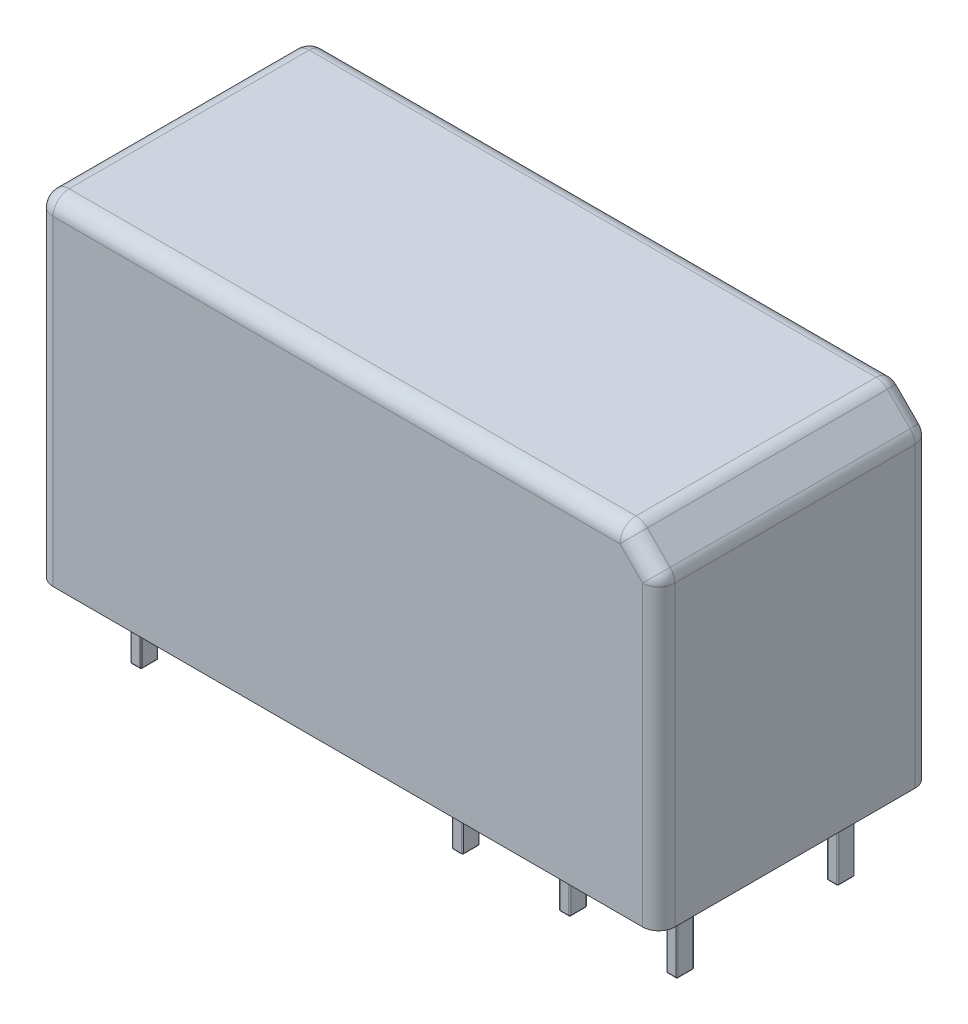
from build123d import *

# Parameters (mm, degrees)
SKETCH_1_W      = 29
SKETCH_1_H      = 12.7
EXTRUDE_1_DEPTH = 15.7
EXTRUDE_2_DEPTH = 3.5
FILLET_1_R      = 0.05
CHAMFER_1_SIZE  = 1.5
FILLET_2_R      = 0.75


with BuildPart() as part:
    # Эскиз1 → Бобышка-Вытянуть1 (new body)
    with BuildSketch(Plane(origin=(0, 0, 0), x_dir=(1, 0, 0), z_dir=(0, 1, 0))):
        Rectangle(SKETCH_1_W, SKETCH_1_H)
    extrude(amount=EXTRUDE_1_DEPTH)

    # Эскиз2 → Бобышка-Вытянуть2 (add)
    with BuildSketch(Plane.XZ):
        with BuildLine():
            Line((-12.3, 4.15), (-11.9, 4.15))
            ThreePointArc((-11.9, 4.15), (-11.864644661, 4.135355339), (-11.85, 4.1))
            Line((-11.85, 4.1), (-11.85, 3.4))
            ThreePointArc((-11.85, 3.4), (-11.864644661, 3.364644661), (-11.9, 3.35))
            Line((-11.9, 3.35), (-12.3, 3.35))
            ThreePointArc((-12.3, 3.35), (-12.335355339, 3.364644661), (-12.35, 3.4))
            Line((-12.35, 3.4), (-12.35, 4.1))
            ThreePointArc((-12.35, 4.1), (-12.335355339, 4.135355339), (-12.3, 4.15))
        make_face()
        with BuildLine():
            Line((2.65, 4.1), (2.65, 3.4))
            ThreePointArc((2.65, 3.4), (2.664644661, 3.364644661), (2.7, 3.35))
            Line((2.7, 3.35), (3.1, 3.35))
            ThreePointArc((3.1, 3.35), (3.135355339, 3.364644661), (3.15, 3.4))
            Line((3.15, 3.4), (3.15, 4.1))
            ThreePointArc((3.15, 4.1), (3.135355339, 4.135355339), (3.1, 4.15))
            Line((3.1, 4.15), (2.7, 4.15))
            ThreePointArc((2.7, 4.15), (2.664644661, 4.135355339), (2.65, 4.1))
        make_face()
        with BuildLine():
            Line((7.65, 4.1), (7.65, 3.4))
            ThreePointArc((7.65, 3.4), (7.664644661, 3.364644661), (7.7, 3.35))
            Line((7.7, 3.35), (8.1, 3.35))
            ThreePointArc((8.1, 3.35), (8.135355339, 3.364644661), (8.15, 3.4))
            Line((8.15, 3.4), (8.15, 4.1))
            ThreePointArc((8.15, 4.1), (8.135355339, 4.135355339), (8.1, 4.15))
            Line((8.1, 4.15), (7.7, 4.15))
            ThreePointArc((7.7, 4.15), (7.664644661, 4.135355339), (7.65, 4.1))
        make_face()
        with BuildLine():
            Line((12.65, 4.1), (12.65, 3.4))
            ThreePointArc((12.65, 3.4), (12.664644661, 3.364644661), (12.7, 3.35))
            Line((12.7, 3.35), (13.1, 3.35))
            ThreePointArc((13.1, 3.35), (13.135355339, 3.364644661), (13.15, 3.4))
            Line((13.15, 3.4), (13.15, 4.1))
            ThreePointArc((13.15, 4.1), (13.135355339, 4.135355339), (13.1, 4.15))
            Line((13.1, 4.15), (12.7, 4.15))
            ThreePointArc((12.7, 4.15), (12.664644661, 4.135355339), (12.65, 4.1))
        make_face()
        with BuildLine():
            Line((2.65, -3.4), (2.65, -4.1))
            ThreePointArc((2.65, -4.1), (2.664644661, -4.135355339), (2.7, -4.15))
            Line((2.7, -4.15), (3.1, -4.15))
            ThreePointArc((3.1, -4.15), (3.135355339, -4.135355339), (3.15, -4.1))
            Line((3.15, -4.1), (3.15, -3.4))
            ThreePointArc((3.15, -3.4), (3.135355339, -3.364644661), (3.1, -3.35))
            Line((3.1, -3.35), (2.7, -3.35))
            ThreePointArc((2.7, -3.35), (2.664644661, -3.364644661), (2.65, -3.4))
        make_face()
        with BuildLine():
            Line((7.65, -3.4), (7.65, -4.1))
            ThreePointArc((7.65, -4.1), (7.664644661, -4.135355339), (7.7, -4.15))
            Line((7.7, -4.15), (8.1, -4.15))
            ThreePointArc((8.1, -4.15), (8.135355339, -4.135355339), (8.15, -4.1))
            Line((8.15, -4.1), (8.15, -3.4))
            ThreePointArc((8.15, -3.4), (8.135355339, -3.364644661), (8.1, -3.35))
            Line((8.1, -3.35), (7.7, -3.35))
            ThreePointArc((7.7, -3.35), (7.664644661, -3.364644661), (7.65, -3.4))
        make_face()
        with BuildLine():
            Line((12.65, -3.4), (12.65, -4.1))
            ThreePointArc((12.65, -4.1), (12.664644661, -4.135355339), (12.7, -4.15))
            Line((12.7, -4.15), (13.1, -4.15))
            ThreePointArc((13.1, -4.15), (13.135355339, -4.135355339), (13.15, -4.1))
            Line((13.15, -4.1), (13.15, -3.4))
            ThreePointArc((13.15, -3.4), (13.135355339, -3.364644661), (13.1, -3.35))
            Line((13.1, -3.35), (12.7, -3.35))
            ThreePointArc((12.7, -3.35), (12.664644661, -3.364644661), (12.65, -3.4))
        make_face()
        with BuildLine():
            Line((-12.35, -3.4), (-12.35, -4.1))
            ThreePointArc((-12.35, -4.1), (-12.335355339, -4.135355339), (-12.3, -4.15))
            Line((-12.3, -4.15), (-11.9, -4.15))
            ThreePointArc((-11.9, -4.15), (-11.864644661, -4.135355339), (-11.85, -4.1))
            Line((-11.85, -4.1), (-11.85, -3.4))
            ThreePointArc((-11.85, -3.4), (-11.864644661, -3.364644661), (-11.9, -3.35))
            Line((-11.9, -3.35), (-12.3, -3.35))
            ThreePointArc((-12.3, -3.35), (-12.335355339, -3.364644661), (-12.35, -3.4))
        make_face()
    extrude(amount=EXTRUDE_2_DEPTH)

    # Скругление1
    fillet_1_edges = [part.edges().sort_by_distance(p)[0] for p in [
        (2.664644661, -3.5, -4.135355339),
        (2.9, -3.5, -4.15),
        (3.135355339, -3.5, -4.135355339),
        (3.15, -3.5, -3.75),
        (3.135355339, -3.5, -3.364644661),
        (2.9, -3.5, -3.35),
        (2.664644661, -3.5, -3.364644661),
        (2.65, -3.5, -3.75),
        (7.664644661, -3.5, -4.135355339),
        (7.9, -3.5, -4.15),
        (8.135355339, -3.5, -4.135355339),
        (8.15, -3.5, -3.75),
        (8.135355339, -3.5, -3.364644661),
        (7.9, -3.5, -3.35),
        (7.664644661, -3.5, -3.364644661),
        (7.65, -3.5, -3.75),
        (12.664644661, -3.5, -4.135355339),
        (12.9, -3.5, -4.15),
        (13.135355339, -3.5, -4.135355339),
        (13.15, -3.5, -3.75),
        (13.135355339, -3.5, -3.364644661),
        (12.9, -3.5, -3.35),
        (12.664644661, -3.5, -3.364644661),
        (12.65, -3.5, -3.75),
        (-12.335355339, -3.5, -4.135355339),
        (-12.1, -3.5, -4.15),
        (-11.864644661, -3.5, -4.135355339),
        (-11.85, -3.5, -3.75),
        (-11.864644661, -3.5, -3.364644661),
        (-12.1, -3.5, -3.35),
        (-12.335355339, -3.5, -3.364644661),
        (-12.35, -3.5, -3.75),
        (-12.335355339, -3.5, 3.364644661),
        (-12.1, -3.5, 3.35),
        (-11.864644661, -3.5, 3.364644661),
        (-11.85, -3.5, 3.75),
        (-11.864644661, -3.5, 4.135355339),
        (-12.1, -3.5, 4.15),
        (-12.335355339, -3.5, 4.135355339),
        (-12.35, -3.5, 3.75),
        (2.664644661, -3.5, 3.364644661),
        (2.9, -3.5, 3.35),
        (3.135355339, -3.5, 3.364644661),
        (3.15, -3.5, 3.75),
        (3.135355339, -3.5, 4.135355339),
        (2.9, -3.5, 4.15),
        (2.664644661, -3.5, 4.135355339),
        (2.65, -3.5, 3.75),
        (7.664644661, -3.5, 3.364644661),
        (7.9, -3.5, 3.35),
        (8.135355339, -3.5, 3.364644661),
        (8.15, -3.5, 3.75),
        (8.135355339, -3.5, 4.135355339),
        (7.9, -3.5, 4.15),
        (7.664644661, -3.5, 4.135355339),
        (7.65, -3.5, 3.75),
        (12.664644661, -3.5, 3.364644661),
        (12.9, -3.5, 3.35),
        (13.135355339, -3.5, 3.364644661),
        (13.15, -3.5, 3.75),
        (13.135355339, -3.5, 4.135355339),
        (12.9, -3.5, 4.15),
        (12.664644661, -3.5, 4.135355339),
        (12.65, -3.5, 3.75),
    ]]
    fillet(fillet_1_edges, radius=FILLET_1_R)

    # Фаска1
    chamfer_1_edges = [part.edges().sort_by_distance(p)[0] for p in [
        (14.5, 15.7, 0),
    ]]
    chamfer(chamfer_1_edges, length=CHAMFER_1_SIZE)

    # Скругление2
    fillet_2_edges = [part.edges().sort_by_distance(p)[0] for p in [
        (-14.5, 15.7, 0),
        (-0.75, 15.7, 6.35),
        (-0.75, 15.7, -6.35),
        (13, 15.7, 0),
        (14.5, 7.1, -6.35),
        (13.75, 14.95, -6.35),
        (14.5, 7.1, 6.35),
        (14.5, 14.2, 0),
        (13.75, 14.95, 6.35),
        (-14.5, 7.85, 6.35),
        (-14.5, 7.85, -6.35),
    ]]
    fillet(fillet_2_edges, radius=FILLET_2_R)


solid = part.part
